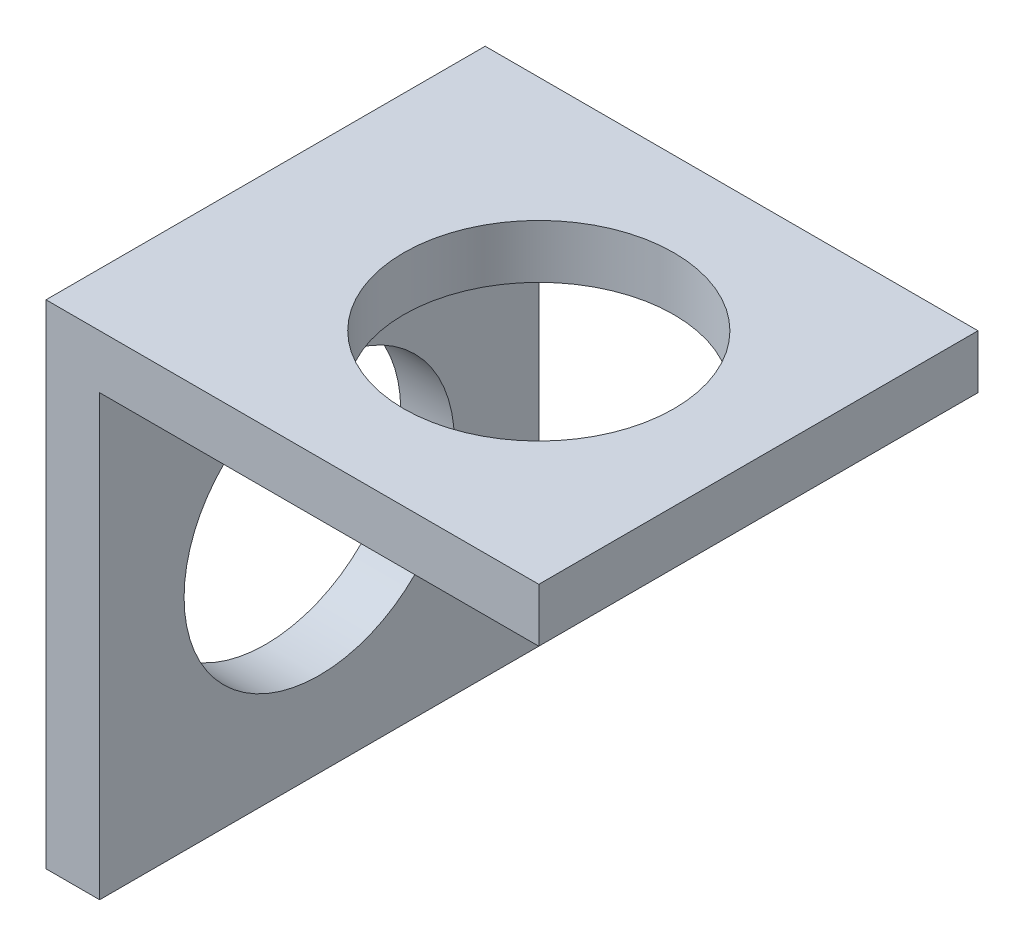
from build123d import *

# Parameters (mm, degrees)
BOSS_EXTRUDE1_DEPTH = 52
SKETCH2_R           = 16
CUT_EXTRUDE1_DEPTH  = 52
SKETCH3_R           = 16
CUT_EXTRUDE2_DEPTH  = 52


with BuildPart() as part:
    # Sketch1 → Boss-Extrude1 (new body)
    with BuildSketch(Plane.XY):
        Polygon((0, 0), (6.35, 0), (6.35, 52), (58.35, 52), (58.35, 58.35), (0, 58.35), (0, 32.973080538), align=None)
    extrude(amount=BOSS_EXTRUDE1_DEPTH)

    # Sketch2 → Cut-Extrude1 (cut)
    with BuildSketch(Plane(origin=(0, 52, 0), x_dir=(-1, 0, 0), z_dir=(0, -1, 0))):
        with Locations((-32.35, -26)):
            Circle(SKETCH2_R)
    extrude(amount=-CUT_EXTRUDE1_DEPTH, mode=Mode.SUBTRACT)

    # Sketch3 → Cut-Extrude2 (cut)
    with BuildSketch(Plane(origin=(6.35, 0, 0), x_dir=(0, 0, -1), z_dir=(1, 0, 0))):
        with Locations((-26, 26)):
            Circle(SKETCH3_R)
    extrude(amount=-CUT_EXTRUDE2_DEPTH, mode=Mode.SUBTRACT)


solid = part.part
